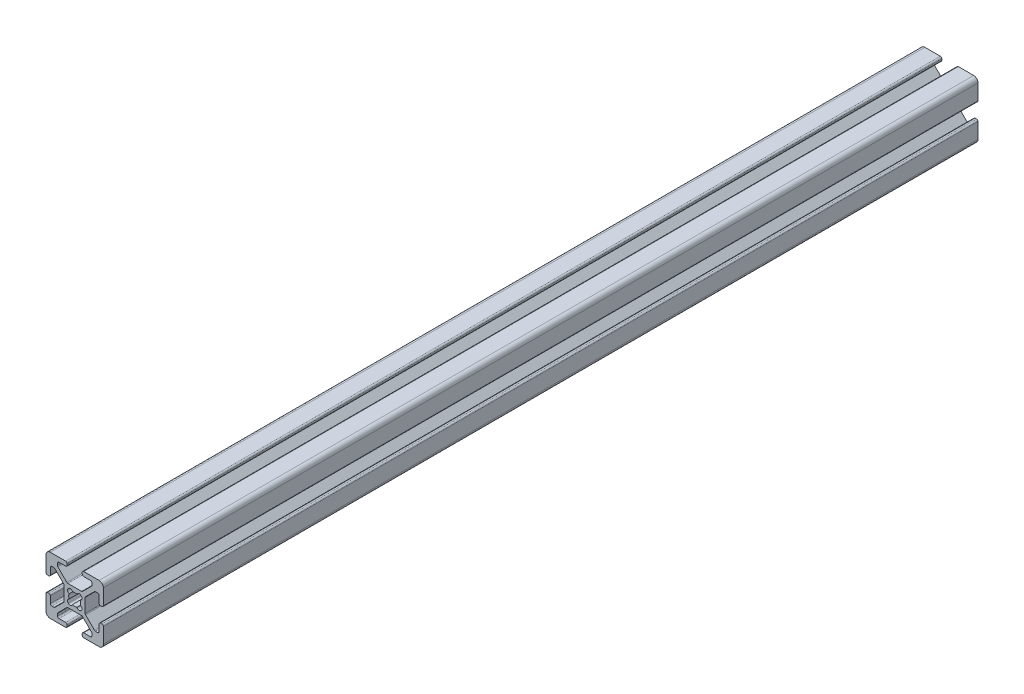
from build123d import *

# Parameters (mm, degrees)
BOSS_EXTRUDE1_DEPTH = 304.8


with BuildPart() as part:
    # Sketch1 → Boss-Extrude1 (new body)
    with BuildSketch(Plane(origin=(0, 0, -457.2), x_dir=(-1, 0, 0), z_dir=(0, 0, -1))):
        with BuildLine():
            Line((10, -8.5), (10, -3.138))
            ThreePointArc((10, -3.138), (9.851210245, -2.778789755), (9.492, -2.63))
            Line((9.492, -2.63), (9.008, -2.63))
            ThreePointArc((9.008, -2.63), (8.648789755, -2.778789755), (8.5, -3.138))
            Line((8.5, -3.138), (8.5, -5.487))
            ThreePointArc((8.5, -5.487), (8.351210245, -5.846210245), (7.992, -5.995))
            Line((7.992, -5.995), (7.26592049, -5.995))
            ThreePointArc((7.26592049, -5.995), (7.071517306, -5.956330803), (6.906710245, -5.846210245))
            Line((6.906710245, -5.846210245), (3.803789755, -2.743289755))
            ThreePointArc((3.803789755, -2.743289755), (3.693669197, -2.578482694), (3.655, -2.38407951))
            Line((3.655, -2.38407951), (3.655, 2.383759167))
            ThreePointArc((3.655, 2.383759167), (3.693669197, 2.57816235), (3.803789755, 2.742969412))
            Line((3.803789755, 2.742969412), (6.907030588, 5.846210245))
            ThreePointArc((6.907030588, 5.846210245), (7.07183765, 5.956330803), (7.266240833, 5.995))
            Line((7.266240833, 5.995), (7.992, 5.995))
            ThreePointArc((7.992, 5.995), (8.351210245, 5.846210245), (8.5, 5.487))
            Line((8.5, 5.487), (8.5, 3.138))
            ThreePointArc((8.5, 3.138), (8.648789755, 2.778789755), (9.008, 2.63))
            Line((9.008, 2.63), (9.492, 2.63))
            ThreePointArc((9.492, 2.63), (9.851210245, 2.778789755), (10, 3.138))
            Line((10, 3.138), (10, 8.5))
            ThreePointArc((10, 8.5), (9.560660172, 9.560660172), (8.5, 10))
            Line((8.5, 10), (3.138, 10))
            ThreePointArc((3.138, 10), (2.778789755, 9.851210245), (2.63, 9.492))
            Line((2.63, 9.492), (2.63, 9.008))
            ThreePointArc((2.63, 9.008), (2.778789755, 8.648789755), (3.138, 8.5))
            Line((3.138, 8.5), (5.487, 8.5))
            ThreePointArc((5.487, 8.5), (5.846210245, 8.351210245), (5.995, 7.992))
            Line((5.995, 7.992), (5.995, 7.26592049))
            ThreePointArc((5.995, 7.26592049), (5.956330803, 7.071517306), (5.846210245, 6.906710245))
            Line((5.846210245, 6.906710245), (2.743289755, 3.803789755))
            ThreePointArc((2.743289755, 3.803789755), (2.578482694, 3.693669197), (2.38407951, 3.655))
            Line((2.38407951, 3.655), (-2.383759167, 3.655))
            ThreePointArc((-2.383759167, 3.655), (-2.57816235, 3.693669197), (-2.742969412, 3.803789755))
            Line((-2.742969412, 3.803789755), (-5.846210245, 6.907030588))
            ThreePointArc((-5.846210245, 6.907030588), (-5.956330803, 7.07183765), (-5.995, 7.266240833))
            Line((-5.995, 7.266240833), (-5.995, 7.992))
            ThreePointArc((-5.995, 7.992), (-5.846210245, 8.351210245), (-5.487, 8.5))
            Line((-5.487, 8.5), (-3.138, 8.5))
            ThreePointArc((-3.138, 8.5), (-2.778789755, 8.648789755), (-2.63, 9.008))
            Line((-2.63, 9.008), (-2.63, 9.492))
            ThreePointArc((-2.63, 9.492), (-2.778789755, 9.851210245), (-3.138, 10))
            Line((-3.138, 10), (-8.5, 10))
            ThreePointArc((-8.5, 10), (-9.560660172, 9.560660172), (-10, 8.5))
            Line((-10, 8.5), (-10, 3.138))
            ThreePointArc((-10, 3.138), (-9.851210245, 2.778789755), (-9.492, 2.63))
            Line((-9.492, 2.63), (-9.008, 2.63))
            ThreePointArc((-9.008, 2.63), (-8.648789755, 2.778789755), (-8.5, 3.138))
            Line((-8.5, 3.138), (-8.5, 5.487))
            ThreePointArc((-8.5, 5.487), (-8.351210245, 5.846210245), (-7.992, 5.995))
            Line((-7.992, 5.995), (-7.26592049, 5.995))
            ThreePointArc((-7.26592049, 5.995), (-7.071517306, 5.956330803), (-6.906710245, 5.846210245))
            Line((-6.906710245, 5.846210245), (-3.803789755, 2.743289755))
            ThreePointArc((-3.803789755, 2.743289755), (-3.693669197, 2.578482694), (-3.655, 2.38407951))
            Line((-3.655, 2.38407951), (-3.655, -2.383759167))
            ThreePointArc((-3.655, -2.383759167), (-3.693669197, -2.57816235), (-3.803789755, -2.742969412))
            Line((-3.803789755, -2.742969412), (-6.907030588, -5.846210245))
            ThreePointArc((-6.907030588, -5.846210245), (-7.07183765, -5.956330803), (-7.266240833, -5.995))
            Line((-7.266240833, -5.995), (-7.992, -5.995))
            ThreePointArc((-7.992, -5.995), (-8.351210245, -5.846210245), (-8.5, -5.487))
            Line((-8.5, -5.487), (-8.5, -3.138))
            ThreePointArc((-8.5, -3.138), (-8.648789755, -2.778789755), (-9.008, -2.63))
            Line((-9.008, -2.63), (-9.492, -2.63))
            ThreePointArc((-9.492, -2.63), (-9.851210245, -2.778789755), (-10, -3.138))
            Line((-10, -3.138), (-10, -8.5))
            ThreePointArc((-10, -8.5), (-9.560660172, -9.560660172), (-8.5, -10))
            Line((-8.5, -10), (-3.138, -10))
            ThreePointArc((-3.138, -10), (-2.778789755, -9.851210245), (-2.63, -9.492))
            Line((-2.63, -9.492), (-2.63, -9.008))
            ThreePointArc((-2.63, -9.008), (-2.778789755, -8.648789755), (-3.138, -8.5))
            Line((-3.138, -8.5), (-5.487, -8.5))
            ThreePointArc((-5.487, -8.5), (-5.846210245, -8.351210245), (-5.995, -7.992))
            Line((-5.995, -7.992), (-5.995, -7.26592049))
            ThreePointArc((-5.995, -7.26592049), (-5.956330803, -7.071517306), (-5.846210245, -6.906710245))
            Line((-5.846210245, -6.906710245), (-2.743289755, -3.803789755))
            ThreePointArc((-2.743289755, -3.803789755), (-2.578482694, -3.693669197), (-2.38407951, -3.655))
            Line((-2.38407951, -3.655), (2.383759167, -3.655))
            ThreePointArc((2.383759167, -3.655), (2.57816235, -3.693669197), (2.742969412, -3.803789755))
            Line((2.742969412, -3.803789755), (5.846210245, -6.907030588))
            ThreePointArc((5.846210245, -6.907030588), (5.956330803, -7.07183765), (5.995, -7.266240833))
            Line((5.995, -7.266240833), (5.995, -7.992))
            ThreePointArc((5.995, -7.992), (5.846210245, -8.351210245), (5.487, -8.5))
            Line((5.487, -8.5), (3.138, -8.5))
            ThreePointArc((3.138, -8.5), (2.778789755, -8.648789755), (2.63, -9.008))
            Line((2.63, -9.008), (2.63, -9.492))
            ThreePointArc((2.63, -9.492), (2.778789755, -9.851210245), (3.138, -10))
            Line((3.138, -10), (8.5, -10))
            ThreePointArc((8.5, -10), (9.560660172, -9.560660172), (10, -8.5))
        make_face()
        with BuildLine():
            Line((2.304493037, -2.124493037), (2.124493037, -2.304493037))
            ThreePointArc((2.124493037, -2.304493037), (1.35638567, -2.506016078), (0.803729988, -1.935777391))
            ThreePointArc((0.803729988, -1.935777391), (0, -2.096), (-0.803729988, -1.935777391))
            ThreePointArc((-0.803729988, -1.935777391), (-1.35638567, -2.506016078), (-2.124493037, -2.304493037))
            Line((-2.124493037, -2.304493037), (-2.304493037, -2.124493037))
            ThreePointArc((-2.304493037, -2.124493037), (-2.506016078, -1.35638567), (-1.935777391, -0.803729988))
            ThreePointArc((-1.935777391, -0.803729988), (-2.096, 0), (-1.935777391, 0.803729988))
            ThreePointArc((-1.935777391, 0.803729988), (-2.506016078, 1.35638567), (-2.304493037, 2.124493037))
            Line((-2.304493037, 2.124493037), (-2.124493037, 2.304493037))
            ThreePointArc((-2.124493037, 2.304493037), (-1.35638567, 2.506016078), (-0.803729988, 1.935777391))
            ThreePointArc((-0.803729988, 1.935777391), (0, 2.096), (0.803729988, 1.935777391))
            ThreePointArc((0.803729988, 1.935777391), (1.35638567, 2.506016078), (2.124493037, 2.304493037))
            Line((2.124493037, 2.304493037), (2.304493037, 2.124493037))
            ThreePointArc((2.304493037, 2.124493037), (2.506016078, 1.35638567), (1.935777391, 0.803729988))
            ThreePointArc((1.935777391, 0.803729988), (2.096, 0), (1.935777391, -0.803729988))
            ThreePointArc((1.935777391, -0.803729988), (2.506016078, -1.35638567), (2.304493037, -2.124493037))
        make_face(mode=Mode.SUBTRACT)
    extrude(amount=-BOSS_EXTRUDE1_DEPTH)


solid = part.part
